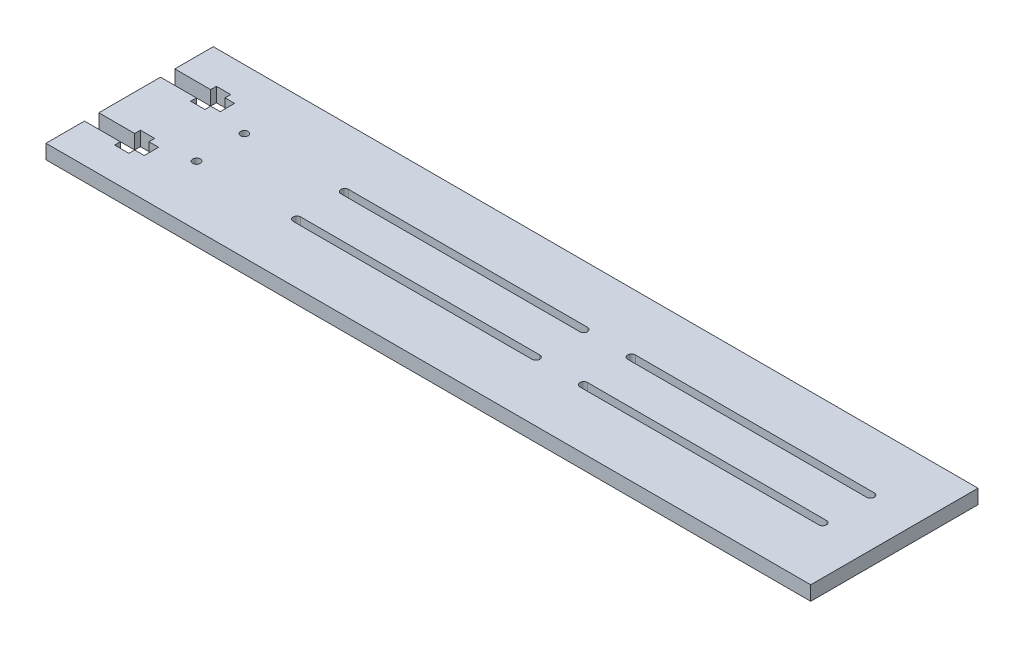
from build123d import *

# Parameters (mm, degrees)
SKETCH1_W           = 320
SKETCH1_H           = 70
BOSS_EXTRUDE1_DEPTH = 6
CUT_EXTRUDE2_DEPTH  = 7
CUT_EXTRUDE3_DEPTH  = 7
SKETCH6_R           = 1.6
CUT_EXTRUDE4_DEPTH  = 7


with BuildPart() as part:
    # Sketch1 → Boss-Extrude1 (new body)
    with BuildSketch(Plane(origin=(0, 0, 0), x_dir=(1, 0, 0), z_dir=(0, 1, 0))):
        Rectangle(SKETCH1_W, SKETCH1_H)
    extrude(amount=BOSS_EXTRUDE1_DEPTH)

    # Sketch3 → Cut-Extrude2 (cut, through all)
    with BuildSketch(Plane(origin=(0, 6, 0), x_dir=(1, 0, 0), z_dir=(0, 1, 0))):
        Polygon((-160, 12.9), (-145, 12.9), (-145, 10.5), (-139, 10.5), (-139, 12.9), (-135, 12.9), (-135, 18.9), (-139, 18.9), (-139, 21.3), (-145, 21.3), (-145, 18.9), (-160, 18.9), align=None)
        Polygon((-145, -18.9), (-145, -21.3), (-139, -21.3), (-139, -18.9), (-135, -18.9), (-135, -12.9), (-139, -12.9), (-139, -10.5), (-145, -10.5), (-145, -12.9), (-160, -12.9), (-160, -18.9), align=None)
    extrude(amount=-CUT_EXTRUDE2_DEPTH, mode=Mode.SUBTRACT)

    # Sketch5 → Cut-Extrude3 (cut, through all)
    with BuildSketch(Plane(origin=(0, 6, 0), x_dir=(1, 0, 0), z_dir=(0, 1, 0))):
        with BuildLine():
            Line((40, -8.4), (140, -8.4))
            ThreePointArc((140, -8.4), (141.6, -10), (140, -11.6))
            Line((140, -11.6), (40, -11.6))
            ThreePointArc((40, -11.6), (38.4, -10), (40, -8.4))
        make_face()
        with BuildLine():
            Line((-80, -8.4), (20, -8.4))
            ThreePointArc((20, -8.4), (21.6, -10), (20, -11.6))
            Line((20, -11.6), (-80, -11.6))
            ThreePointArc((-80, -11.6), (-81.6, -10), (-80, -8.4))
        make_face()
        with BuildLine():
            Line((-80, 11.6), (20, 11.6))
            ThreePointArc((20, 11.6), (21.6, 10), (20, 8.4))
            Line((20, 8.4), (-80, 8.4))
            ThreePointArc((-80, 8.4), (-81.6, 10), (-80, 11.6))
        make_face()
        with BuildLine():
            Line((40, 11.6), (140, 11.6))
            ThreePointArc((140, 11.6), (141.6, 10), (140, 8.4))
            Line((140, 8.4), (40, 8.4))
            ThreePointArc((40, 8.4), (38.4, 10), (40, 11.6))
        make_face()
    extrude(amount=-CUT_EXTRUDE3_DEPTH, mode=Mode.SUBTRACT)

    # Sketch6 → Cut-Extrude4 (cut, through all)
    with BuildSketch(Plane.XZ):
        with Locations((-122, -10)):
            Circle(SKETCH6_R)
        with Locations((-122, 10)):
            Circle(SKETCH6_R)
    extrude(amount=-CUT_EXTRUDE4_DEPTH, mode=Mode.SUBTRACT)


solid = part.part
